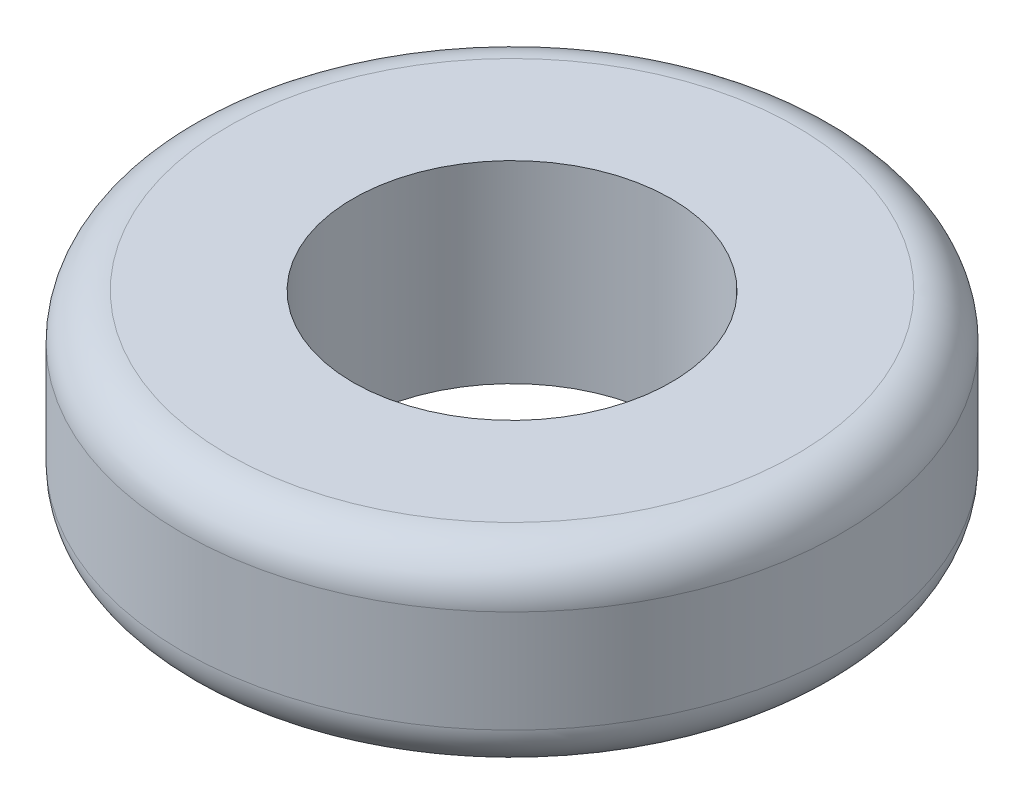
from build123d import *

# Parameters (mm, degrees)
SKETCH1_R           = 7.25
SKETCH1_R_2         = 3.5
BOSS_EXTRUDE1_DEPTH = 4.25
FILLET1_R           = 1


with BuildPart() as part:
    # Sketch1 → Boss-Extrude1 (new body)
    with BuildSketch(Plane(origin=(0, 0, 0), x_dir=(1, 0, 0), z_dir=(0, 1, 0))):
        Circle(SKETCH1_R)
        Circle(SKETCH1_R_2, mode=Mode.SUBTRACT)
    extrude(amount=BOSS_EXTRUDE1_DEPTH)

    # Fillet1
    fillet1_edges = [part.edges().sort_by_distance(p)[0] for p in [
        (-7.25, 0, 0),
        (-7.25, 4.25, 0),
    ]]
    fillet(fillet1_edges, radius=FILLET1_R)


solid = part.part
